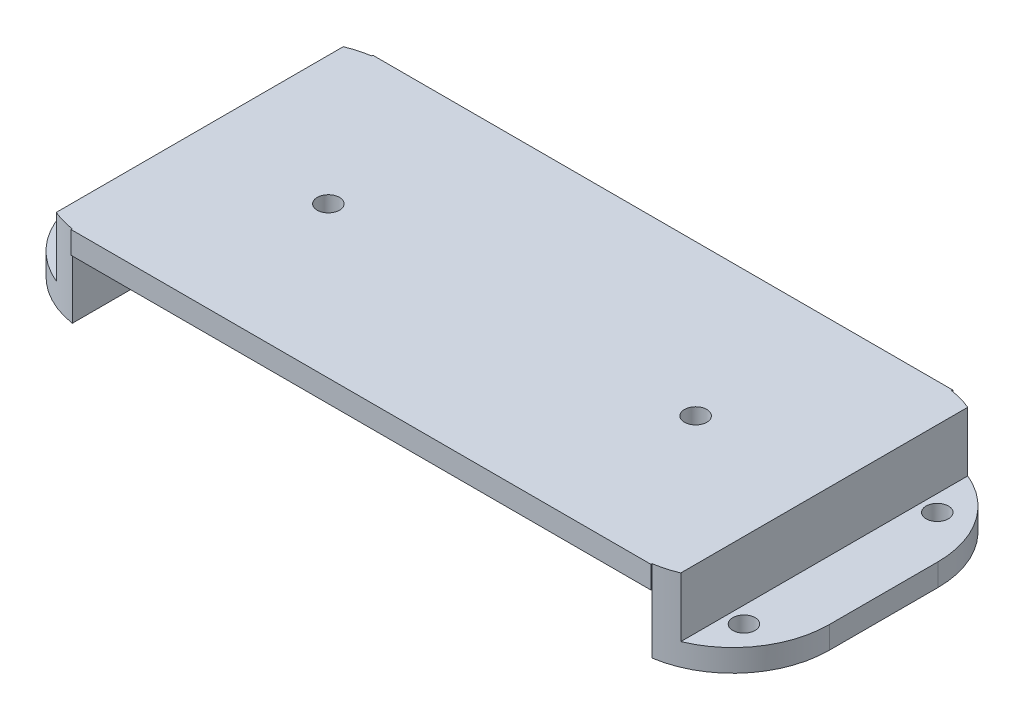
from build123d import *

# Parameters (mm, degrees)
BOSS_EXTRUDE1_DEPTH = 40.6
SKETCH2_R           = 1.5
CUT_EXTRUDE3_DEPTH  = 24
SKETCH5_R           = 1.5
CUT_EXTRUDE4_DEPTH  = 4


with BuildPart() as part:
    # Sketch1 → Boss-Extrude1 (new body)
    with BuildSketch(Plane.XY):
        Polygon((8.125196993, -3.6), (8.125196993, -11.6), (0.125196993, -11.6), (0.125196993, -14.6), (11.125196993, -14.6), (11.125196993, -6.6), (89.125196993, -6.6), (89.125196993, -14.6), (100.125196993, -14.6), (100.125196993, -11.6), (92.125196993, -11.6), (92.125196993, -3.6), align=None)
    extrude(amount=BOSS_EXTRUDE1_DEPTH)

    # Sketch2 → Cut-Extrude3 (cut)
    with BuildSketch(Plane.XZ.offset(14.6)):
        with BuildLine():
            Line((89.125196993, 0.154767421), (89.125196993, 0))
            Line((89.125196993, 0), (100.125196993, 0))
            Line((100.125196993, 0), (100.125196993, 13))
            ThreePointArc((100.125196993, 13), (96.999405822, 4.544232737), (89.125196993, 0.154767421))
        make_face()
        with BuildLine():
            Line((89.125196993, 40.6), (89.125196993, 40.445232579))
            ThreePointArc((89.125196993, 40.445232579), (96.999405822, 36.055767263), (100.125196993, 27.6))
            Line((100.125196993, 27.6), (100.125196993, 40.6))
            Line((100.125196993, 40.6), (89.125196993, 40.6))
        make_face()
        with BuildLine():
            Line((0.125196993, 0), (11.125196993, 0))
            Line((11.125196993, 0), (11.125196993, 0.154767421))
            ThreePointArc((11.125196993, 0.154767421), (3.250988164, 4.544232737), (0.125196993, 13))
            Line((0.125196993, 13), (0.125196993, 0))
        make_face()
        with BuildLine():
            ThreePointArc((0.125196993, 27.6), (3.250988164, 36.055767263), (11.125196993, 40.445232579))
            Line((11.125196993, 40.445232579), (11.125196993, 40.6))
            Line((11.125196993, 40.6), (0.125196993, 40.6))
            Line((0.125196993, 40.6), (0.125196993, 27.6))
        make_face()
        with Locations((94.325196993, 33.3)):
            Circle(SKETCH2_R)
        with Locations((94.325196993, 7.3)):
            Circle(SKETCH2_R)
        with Locations((5.925196993, 33.3)):
            Circle(SKETCH2_R)
        with Locations((5.925196993, 7.3)):
            Circle(SKETCH2_R)
    extrude(amount=-CUT_EXTRUDE3_DEPTH, mode=Mode.SUBTRACT)

    # Sketch5 → Cut-Extrude4 (cut)
    with BuildSketch(Plane(origin=(0, -3.6, 0), x_dir=(1, 0, 0), z_dir=(0, 1, 0))):
        with Locations((25.425196993, -20.3)):
            Circle(SKETCH5_R)
        with Locations((74.825196993, -20.3)):
            Circle(SKETCH5_R)
    extrude(amount=-CUT_EXTRUDE4_DEPTH, mode=Mode.SUBTRACT)


solid = part.part
